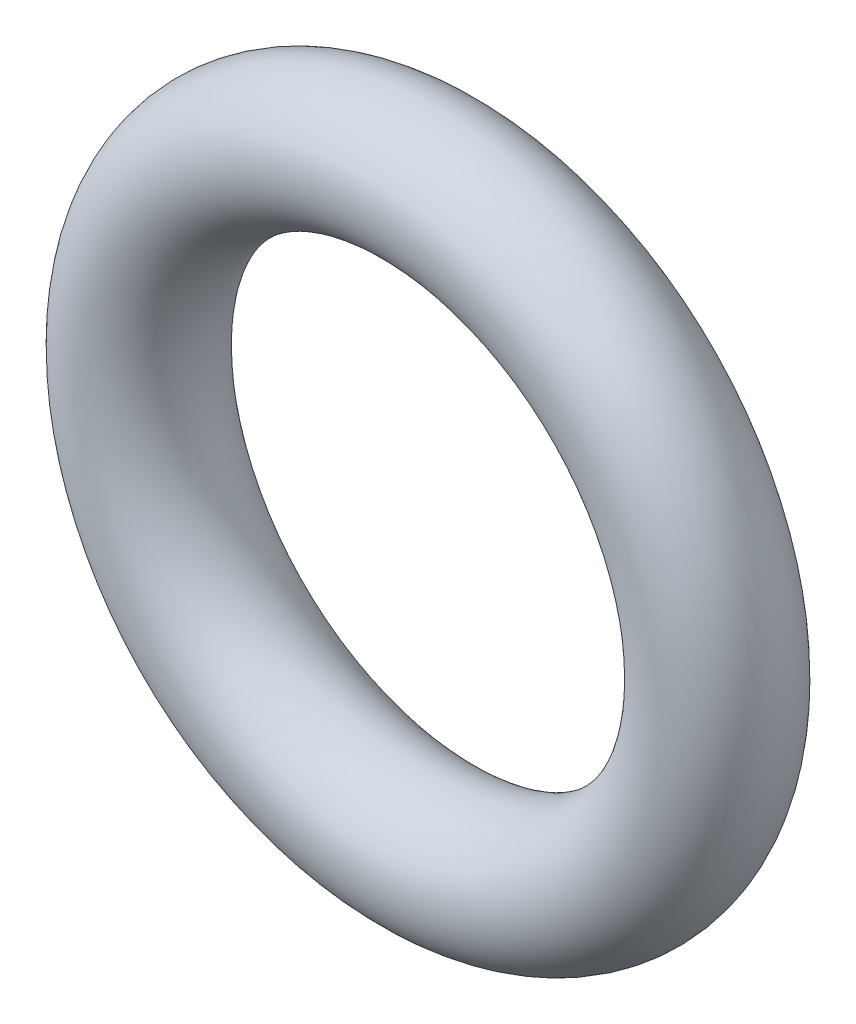
from build123d import *

# Parameters (mm, degrees)
SKETCH1_R = 0.889


with BuildPart() as part:
    # Sketch1 → Revolve1 (revolve)
    with BuildSketch(Plane(origin=(0, 0, 0), x_dir=(0, -1, 0), z_dir=(1, 0, 0))):
        with Locations((3.9243, 0)):
            Circle(SKETCH1_R)
    revolve(axis=Axis((0, 0, 0.889), (0, 0, -1)))


solid = part.part
